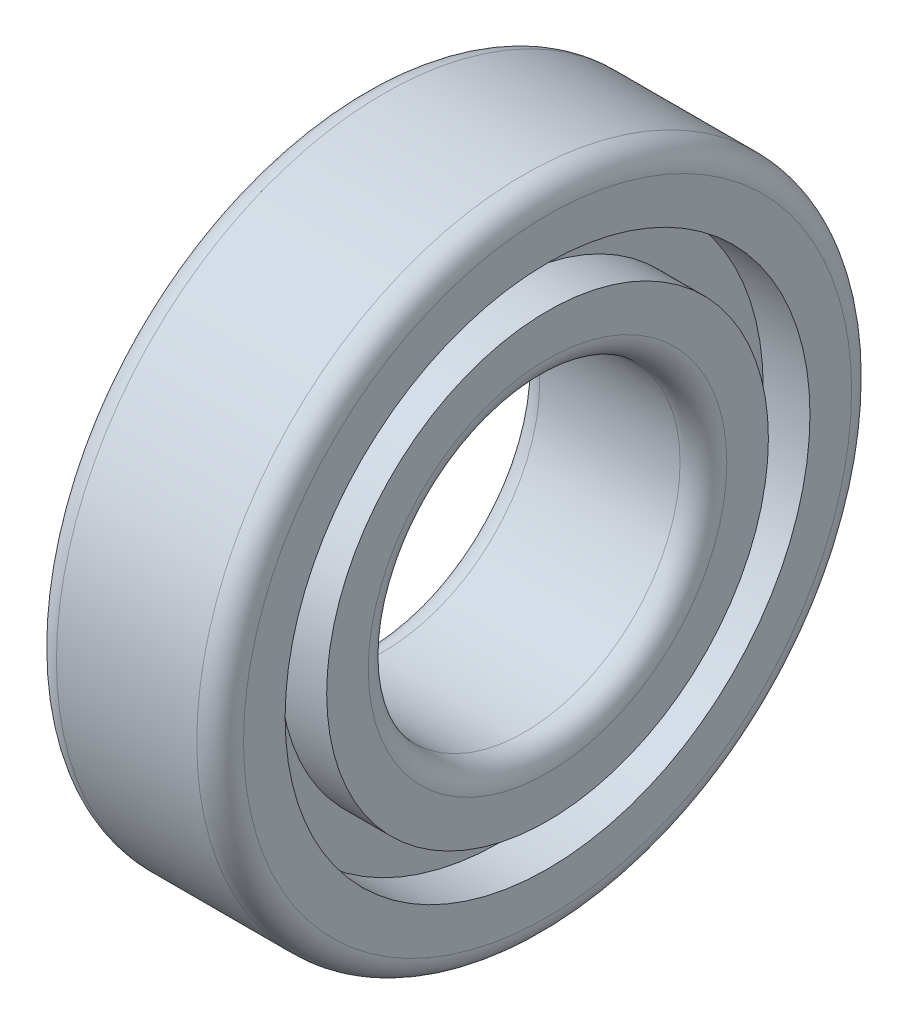
from build123d import *


with BuildPart() as part:
    # Эскиз1 → Повернуть1 (revolve)
    with BuildSketch(Plane.XY):
        with BuildLine():
            Line((4.5, 10), (-4.5, 10))
            ThreePointArc((-4.5, 10), (-5.560660172, 10.439339828), (-6, 11.5))
            Line((-6, 11.5), (-6, 14.166666667))
            Line((-6, 14.166666667), (-3, 14.166666667))
            Line((-3, 14.166666667), (-3, 16.833333333))
            Line((-3, 16.833333333), (-6, 16.833333333))
            Line((-6, 16.833333333), (-6, 19.5))
            ThreePointArc((-6, 19.5), (-5.560660172, 20.560660172), (-4.5, 21))
            Line((-4.5, 21), (4.5, 21))
            ThreePointArc((4.5, 21), (5.560660172, 20.560660172), (6, 19.5))
            Line((6, 19.5), (6, 16.833333333))
            Line((6, 16.833333333), (3, 16.833333333))
            Line((3, 16.833333333), (3, 14.166666667))
            Line((3, 14.166666667), (6, 14.166666667))
            Line((6, 14.166666667), (6, 11.5))
            ThreePointArc((6, 11.5), (5.560660172, 10.439339828), (4.5, 10))
        make_face()
    revolve(axis=Axis((-873.991742101, 0, 0), (1, 0, 0)))


solid = part.part
